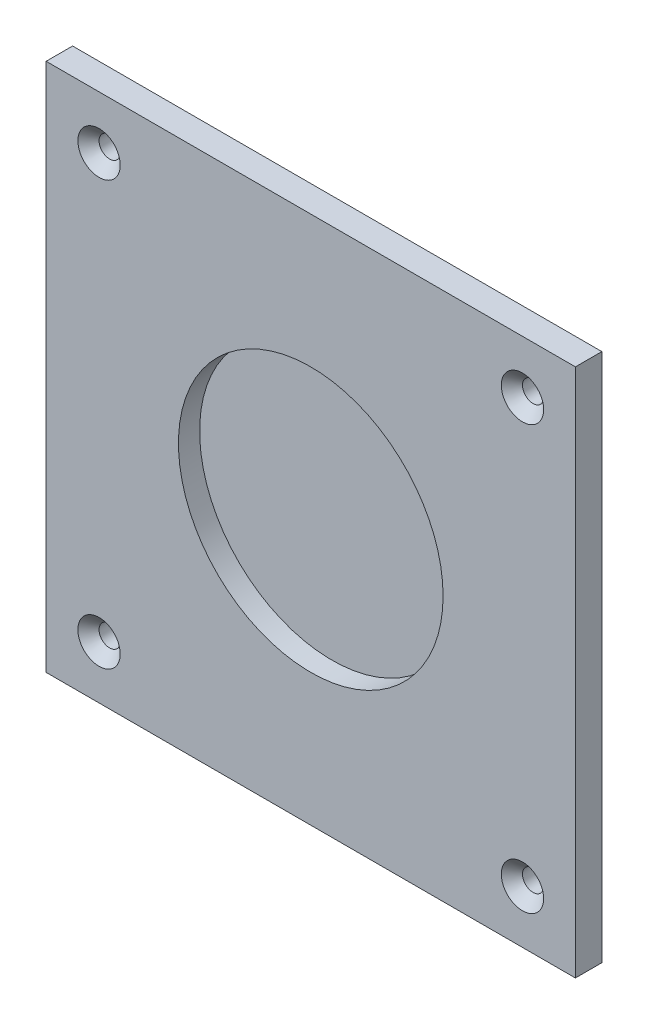
from build123d import *

# Parameters (mm, degrees)
SKETCH1_W           = 2540
SKETCH1_H           = 2540
BOSS_EXTRUDE1_DEPTH = 127
SKETCH2_R           = 635
CUT_EXTRUDE1_DEPTH  = 101.6
CIRPATTERN1_COUNT   = 4


with BuildPart() as part:
    # Sketch1 → Boss-Extrude1 (new body)
    with BuildSketch(Plane.XY):
        Rectangle(SKETCH1_W, SKETCH1_H)
    extrude(amount=-BOSS_EXTRUDE1_DEPTH)

    # Sketch2 → Cut-Extrude1 (cut)
    with BuildSketch(Plane.XY):
        Circle(SKETCH2_R)
    extrude(amount=-CUT_EXTRUDE1_DEPTH, mode=Mode.SUBTRACT)

    # Sketch3 → Cut-Revolve1 (revolve, cut)
    with BuildSketch(Plane(origin=(1016, 0, 0), x_dir=(0, 0, -1), z_dir=(1, 0, 0))):
        Polygon((127, 1066.8), (50.8, 1066.8), (0, 1117.6), (0, 1016), (127, 1016), align=None)
    cut_revolve1 = revolve(axis=Axis((1016, 1016, -127), (0, 0, 1)), mode=Mode.SUBTRACT)

    # CirPattern1: Cut-Revolve1 ×4 about axis
    cirpattern1_axis = Axis((0, 0, 0), (0, 0, 1))
    for i in range(1, CIRPATTERN1_COUNT):
        add(cut_revolve1.rotate(cirpattern1_axis, i * 360 / CIRPATTERN1_COUNT), mode=Mode.SUBTRACT)


solid = part.part
